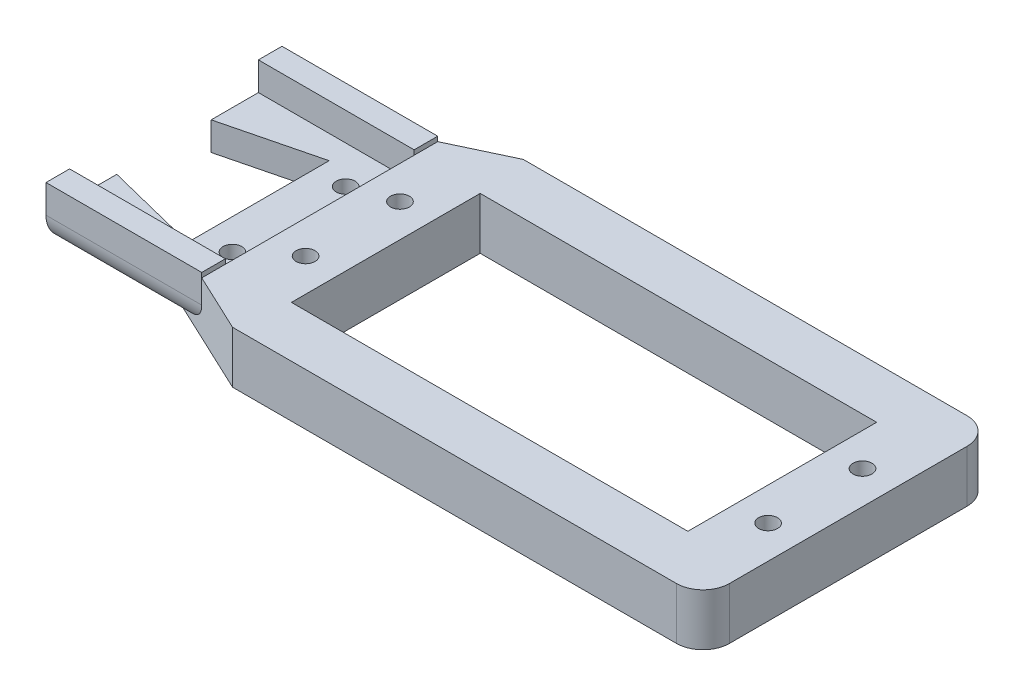
from build123d import *

# Parameters (mm, degrees)
CROQUIS1_R              = 1.000000216
CROQUIS1_R_2            = 1.000000063
CROQUIS1_R_3            = 1.000000073
CROQUIS1_R_4            = 0.999999979
CROQUIS1_R_5            = 1.000000424
CROQUIS1_R_6            = 1.000000593
CROQUIS1_W              = 42
CROQUIS1_H              = 20
SALIENTE_EXTRUIR1_DEPTH = 5.5
CROQUIS2_W              = 16.5
CROQUIS2_H              = 2.5
SALIENTE_EXTRUIR2_DEPTH = 0.5
CROQUIS3_W              = 16.5
CROQUIS3_H              = 20
CORTAR_EXTRUIR1_DEPTH   = 2.5
REDONDEO1_R             = 3


with BuildPart() as part:
    # Croquis1 → Saliente-Extruir1 (new body)
    with BuildSketch(Plane(origin=(0, 0, 0), x_dir=(1, 0, 0), z_dir=(0, 1, 0))):
        with BuildLine():
            Line((-35.503347099, 12.623865495), (-35.503347099, 5.124115358))
            Line((-35.503347099, 5.124115358), (-25.50434655, 7.623865495))
            Line((-25.50434655, 7.623865495), (-25.50434655, -7.376134505))
            Line((-25.50434655, -7.376134505), (-35.503347099, -4.876384368))
            Line((-35.503347099, -4.876384368), (-35.503347099, -12.376134505))
            Line((-35.503347099, -12.376134505), (-19.003347099, -12.376134505))
            Line((-19.003347099, -12.376134505), (-12.8396222, -15.276134123))
            Line((-12.8396222, -15.276134123), (34.184025109, -15.270214667))
            ThreePointArc((34.184025109, -15.270214667), (36.167856769, -14.448338396), (36.98973304, -12.464506735))
            Line((36.98973304, -12.464506735), (36.98973304, 12.712237726))
            ThreePointArc((36.98973304, 12.712237726), (36.167960213, 14.69617283), (34.184025109, 15.517945657))
            Line((34.184025109, 15.517945657), (-12.8396222, 15.523865114))
            Line((-12.8396222, 15.523865114), (-19.003347099, 12.623865495))
            Line((-19.003347099, 12.623865495), (-35.503347099, 12.623865495))
        make_face()
        with Locations((-22.254346372, 6.123865279)):
            Circle(CROQUIS1_R, mode=Mode.SUBTRACT)
        with Locations((-15.504346839, 5.123865558)):
            Circle(CROQUIS1_R_2, mode=Mode.SUBTRACT)
        with Locations((33.495653377, 5.123865568)):
            Circle(CROQUIS1_R_3, mode=Mode.SUBTRACT)
        with Locations((33.4956531, -4.876133997)):
            Circle(CROQUIS1_R_4, mode=Mode.SUBTRACT)
        with Locations((-15.504347678, -4.876134927)):
            Circle(CROQUIS1_R_5, mode=Mode.SUBTRACT)
        with Locations((-22.254345484, -5.876135091)):
            Circle(CROQUIS1_R_6, mode=Mode.SUBTRACT)
        with Locations((8.99565345, 0.123865495)):
            Rectangle(CROQUIS1_W, CROQUIS1_H, mode=Mode.SUBTRACT)
    extrude(amount=SALIENTE_EXTRUIR1_DEPTH)

    # Croquis2 → Saliente-Extruir2 (add)
    with BuildSketch(Plane(origin=(0, 5.5, 0), x_dir=(1, 0, 0), z_dir=(0, 1, 0))):
        with Locations((-27.253347099, -11.126134505)):
            Rectangle(CROQUIS2_W, CROQUIS2_H)
        with Locations((-27.253347099, 11.373865495)):
            Rectangle(CROQUIS2_W, CROQUIS2_H)
    extrude(amount=SALIENTE_EXTRUIR2_DEPTH)

    # Croquis3 → Cortar-Extruir1 (cut)
    with BuildSketch(Plane(origin=(0, 5.5, 0), x_dir=(1, 0, 0), z_dir=(0, 1, 0))):
        with Locations((-27.253347099, 0.123865495)):
            Rectangle(CROQUIS3_W, CROQUIS3_H)
    extrude(amount=-CORTAR_EXTRUIR1_DEPTH, mode=Mode.SUBTRACT)

    # Redondeo1
    redondeo1_edges = [part.edges().sort_by_distance(p)[0] for p in [
        (-27.253347099, 0, 12.376134505),
        (-27.253347099, 0, -12.623865495),
    ]]
    fillet(redondeo1_edges, radius=REDONDEO1_R)


solid = part.part
